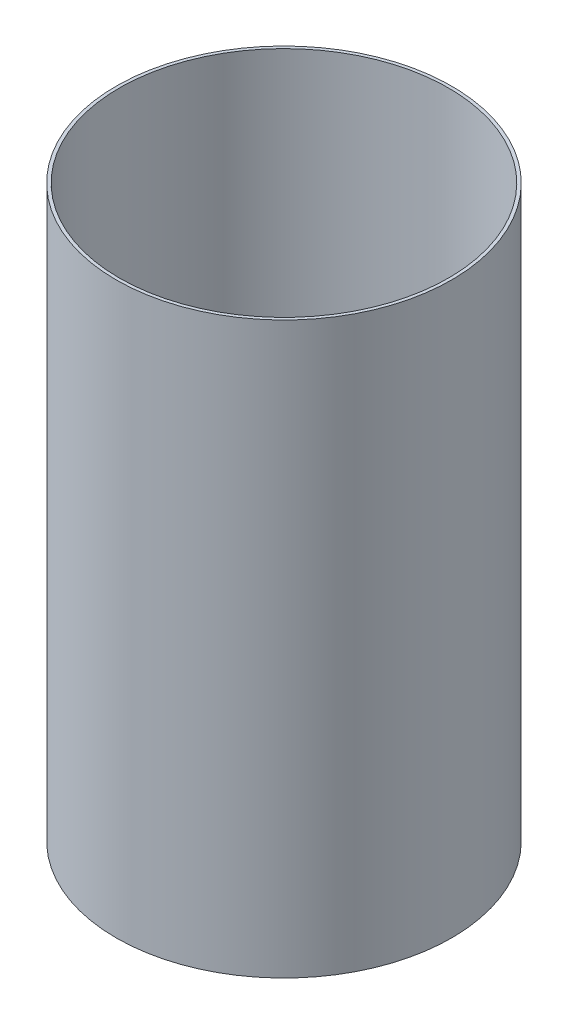
from build123d import *

# Parameters (mm, degrees)
SKETCH1_R           = 67.31
SKETCH1_R_2         = 66.04
BOSS_EXTRUDE1_DEPTH = 114.3


with BuildPart() as part:
    # Sketch1 → Boss-Extrude1 (new, symmetric)
    with BuildSketch(Plane(origin=(0, 0, 0), x_dir=(1, 0, 0), z_dir=(0, 1, 0))):
        Circle(SKETCH1_R)
        Circle(SKETCH1_R_2, mode=Mode.SUBTRACT)
    extrude(amount=BOSS_EXTRUDE1_DEPTH, both=True)


solid = part.part
